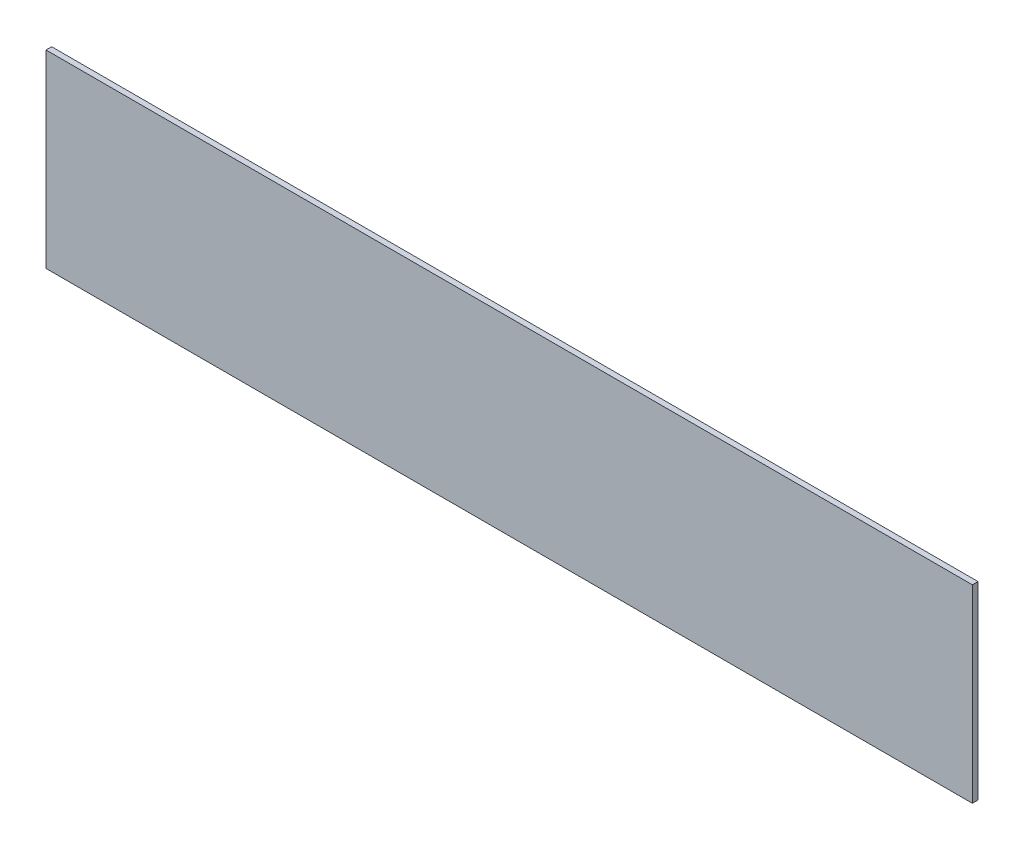
from build123d import *

# Parameters (mm, degrees)
SKETCH1_W           = 1041.4
SKETCH1_H           = 212.725
BOSS_EXTRUDE1_DEPTH = 6.35


with BuildPart() as part:
    # Sketch1 → Boss-Extrude1 (new body)
    with BuildSketch(Plane.XY):
        Rectangle(SKETCH1_W, SKETCH1_H)
    extrude(amount=BOSS_EXTRUDE1_DEPTH)


solid = part.part
